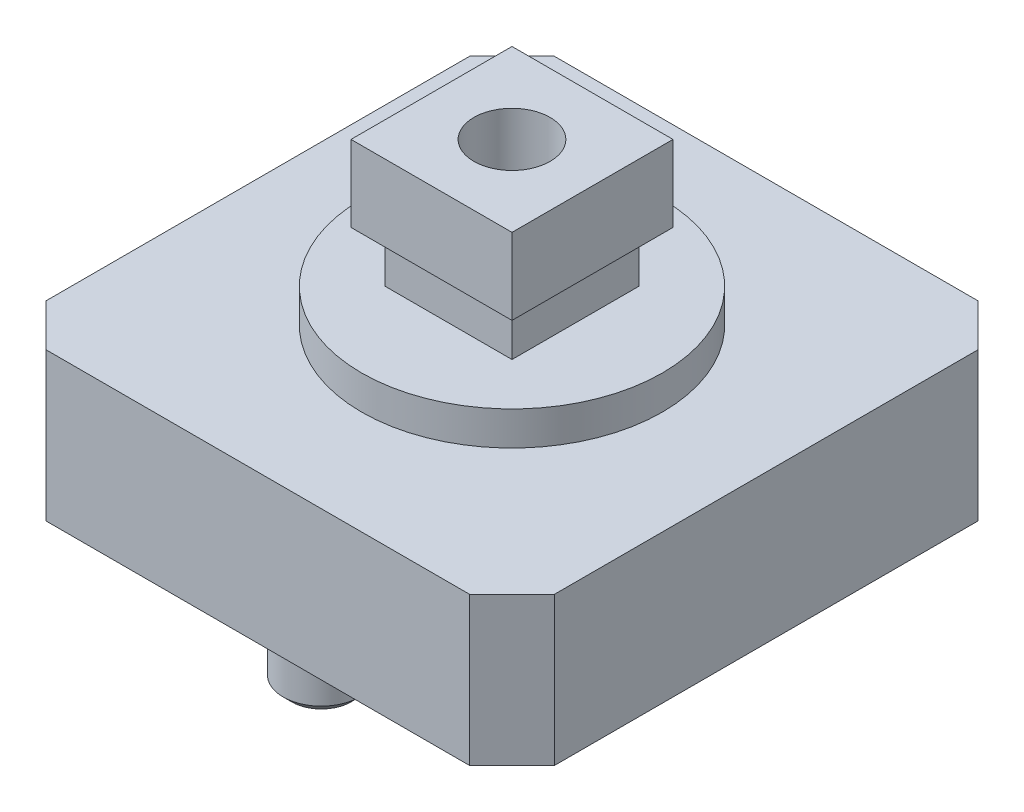
from build123d import *

# Parameters (mm, degrees)
BOSS_EXTRUDE1_DEPTH = 3.5
SKETCH2_R           = 0.9
BOSS_EXTRUDE2_DEPTH = 1.6
CHAMFER1_SIZE       = 0.2
SKETCH3_R           = 3.55
BOSS_EXTRUDE3_DEPTH = 0.8
SKETCH4_W           = 3
SKETCH4_H           = 3
BOSS_EXTRUDE4_DEPTH = 1.2
SKETCH5_W           = 3.8
SKETCH5_H           = 3.8
BOSS_EXTRUDE5_DEPTH = 1.8
SKETCH6_R           = 0.9
CUT_EXTRUDE1_DEPTH  = 2


with BuildPart() as part:
    # Sketch1 → Boss-Extrude1 (new body)
    with BuildSketch(Plane(origin=(0, 0, 0), x_dir=(1, 0, 0), z_dir=(0, 1, 0))):
        Polygon((-6, 5), (-5, 6), (5, 6), (6, 5), (6, -5), (5, -6), (-5, -6), (-6, -5), align=None)
    extrude(amount=BOSS_EXTRUDE1_DEPTH)

    # Sketch2 → Boss-Extrude2 (add)
    with BuildSketch(Plane.XZ):
        with Locations((0, -4.5)):
            Circle(SKETCH2_R)
        with Locations((0, 4.5)):
            Circle(SKETCH2_R)
    extrude(amount=BOSS_EXTRUDE2_DEPTH)

    # Chamfer1
    chamfer1_edges = [part.edges().sort_by_distance(p)[0] for p in [
        (-0.9, -1.6, -4.5),
        (-0.9, -1.6, 4.5),
    ]]
    chamfer(chamfer1_edges, length=CHAMFER1_SIZE)

    # Sketch3 → Boss-Extrude3 (add)
    with BuildSketch(Plane(origin=(0, 3.5, 0), x_dir=(1, 0, 0), z_dir=(0, 1, 0))):
        Circle(SKETCH3_R)
    extrude(amount=BOSS_EXTRUDE3_DEPTH)

    # Sketch4 → Boss-Extrude4 (add)
    with BuildSketch(Plane(origin=(0, 4.3, 0), x_dir=(1, 0, 0), z_dir=(0, 1, 0))):
        Rectangle(SKETCH4_W, SKETCH4_H)
    extrude(amount=BOSS_EXTRUDE4_DEPTH)

    # Sketch5 → Boss-Extrude5 (add)
    with BuildSketch(Plane(origin=(0, 5.5, 0), x_dir=(1, 0, 0), z_dir=(0, 1, 0))):
        Rectangle(SKETCH5_W, SKETCH5_H)
    extrude(amount=BOSS_EXTRUDE5_DEPTH)

    # Sketch6 → Cut-Extrude1 (cut)
    with BuildSketch(Plane(origin=(0, 7.3, 0), x_dir=(1, 0, 0), z_dir=(0, 1, 0))):
        Circle(SKETCH6_R)
    extrude(amount=-CUT_EXTRUDE1_DEPTH, mode=Mode.SUBTRACT)


solid = part.part
